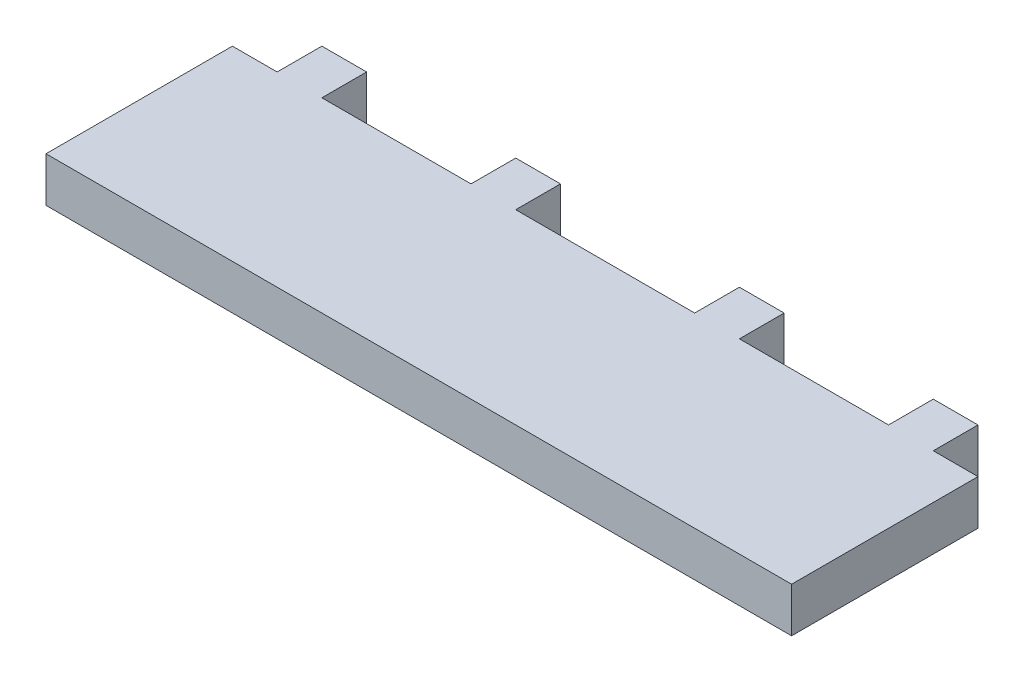
from build123d import *

# Parameters (mm, degrees)
SKETCH1_W           = 100
SKETCH1_H           = 6
BOSS_EXTRUDE1_DEPTH = 25
SKETCH4_W           = 6
SKETCH4_H           = 6
BOSS_EXTRUDE4_DEPTH = 6


with BuildPart() as part:
    # Sketch1 → Boss-Extrude1 (new body)
    with BuildSketch(Plane.XY):
        with Locations((0, 3)):
            Rectangle(SKETCH1_W, SKETCH1_H)
    extrude(amount=BOSS_EXTRUDE1_DEPTH)

    # Sketch4 → Boss-Extrude4 (add)
    with BuildSketch(Plane(origin=(0, 0, 0), x_dir=(-1, 0, 0), z_dir=(0, 0, -1))):
        with Locations((-41, 3)):
            Rectangle(SKETCH4_W, SKETCH4_H)
        with Locations((-15, 3)):
            Rectangle(SKETCH4_W, SKETCH4_H)
        with Locations((15, 3)):
            Rectangle(SKETCH4_W, SKETCH4_H)
        with Locations((41, 3)):
            Rectangle(SKETCH4_W, SKETCH4_H)
    extrude(amount=BOSS_EXTRUDE4_DEPTH)


solid = part.part
